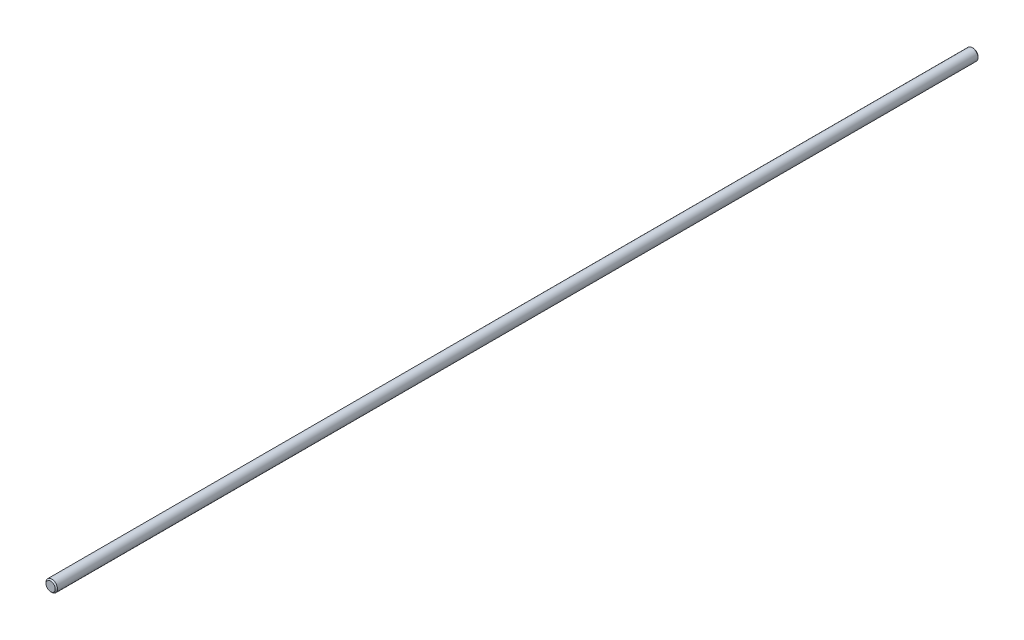
from build123d import *

# Parameters (mm, degrees)
SKETCH1_R      = 2.5
EXTRUDE1_DEPTH = 200
CHAMFER1_SIZE  = 0.5


with BuildPart() as part:
    # Sketch1 → Extrude1 (new body, symmetric)
    with BuildSketch(Plane.XY):
        Circle(SKETCH1_R)
    extrude(amount=EXTRUDE1_DEPTH, both=True)

    # Chamfer1
    chamfer1_edges = [part.edges().sort_by_distance(p)[0] for p in [
        (-2.5, 0, -200),
        (-2.5, 0, 200),
    ]]
    chamfer(chamfer1_edges, length=CHAMFER1_SIZE)


solid = part.part
